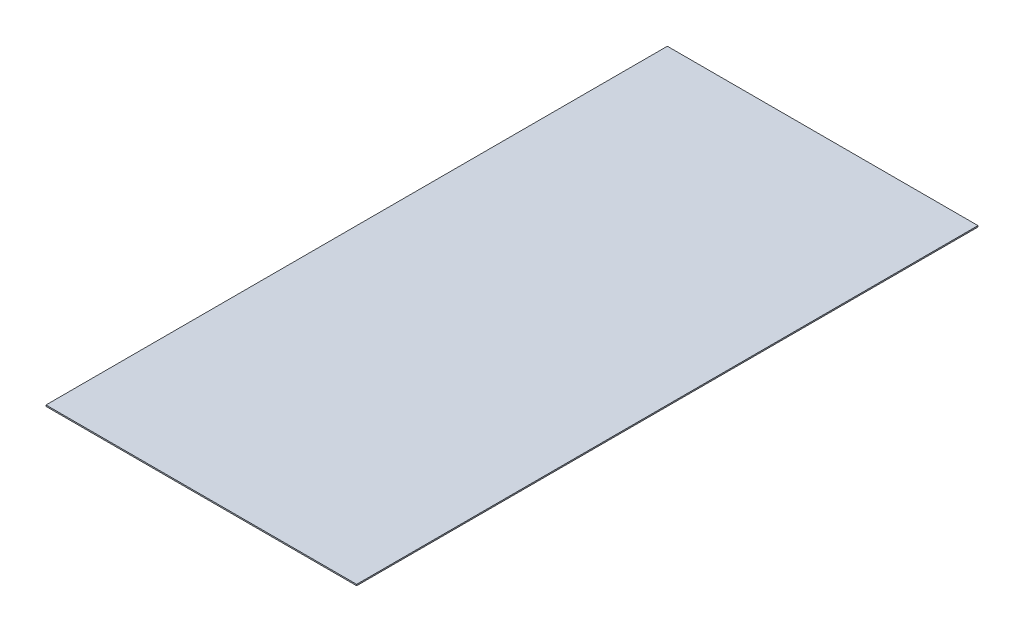
from build123d import *

# Parameters (mm, degrees)
SKETCH_1_W      = 1220
SKETCH_1_H      = 2440
EXTRUDE_1_DEPTH = 5


with BuildPart() as part:
    # 草图1 → 凸台-拉伸1 (new body)
    with BuildSketch(Plane(origin=(0, 0, 0), x_dir=(1, 0, 0), z_dir=(0, 1, 0))):
        Rectangle(SKETCH_1_W, SKETCH_1_H)
    extrude(amount=EXTRUDE_1_DEPTH)


solid = part.part
